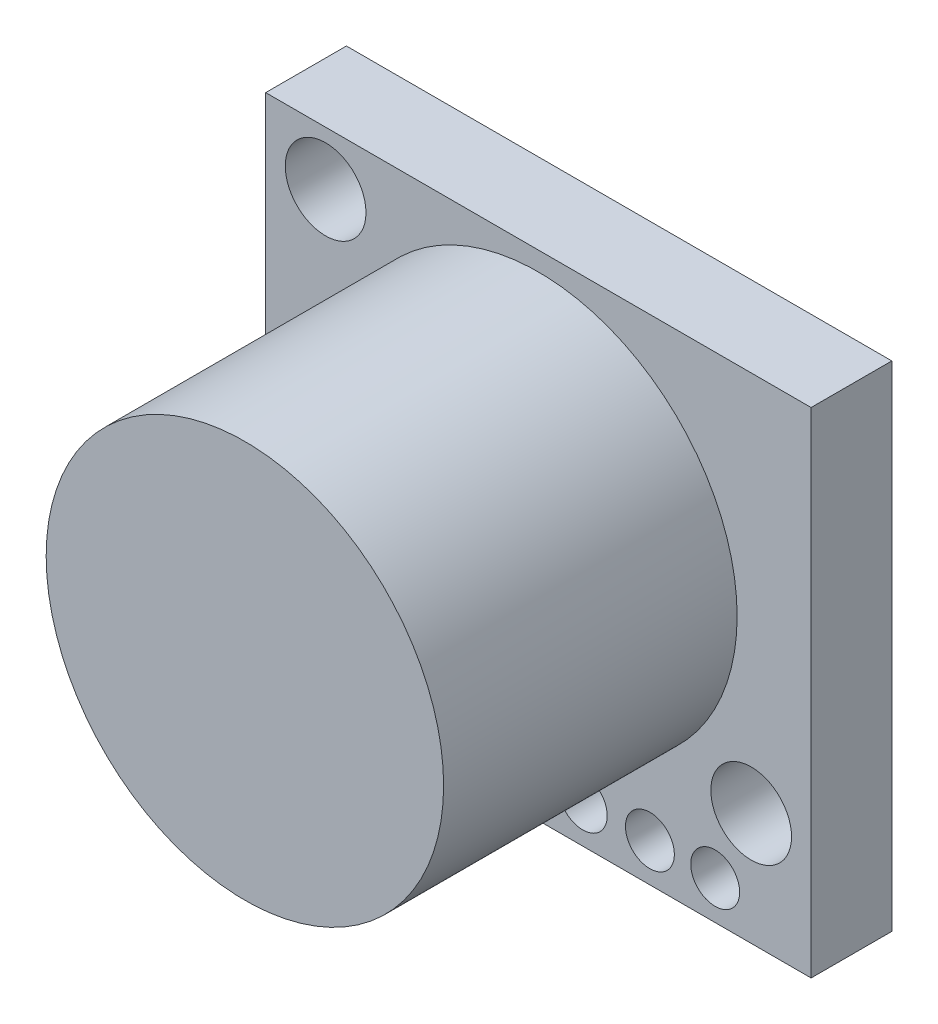
from build123d import *

# Parameters (mm, degrees)
SKETCH1_W           = 22.3
SKETCH1_H           = 20.2
SKETCH1_R           = 1.65
BOSS_EXTRUDE1_DEPTH = 3.3
SKETCH2_R           = 8.125
BOSS_EXTRUDE2_DEPTH = 12
SKETCH2_3_R         = 1
CUT_EXTRUDE1_DEPTH  = 12


with BuildPart() as part:
    # Sketch1 → Boss-Extrude1 (new body)
    with BuildSketch(Plane.XY):
        with Locations((11.15, 10.1)):
            Rectangle(SKETCH1_W, SKETCH1_H)
        with Locations((2.45, 18)):
            Circle(SKETCH1_R, mode=Mode.SUBTRACT)
        with Locations((19.85, 4.6)):
            Circle(SKETCH1_R, mode=Mode.SUBTRACT)
    extrude(amount=BOSS_EXTRUDE1_DEPTH)

    # Sketch2 → Boss-Extrude2 (add)
    with BuildSketch(Plane.XY.offset(3.3)):
        with Locations((11.15, 11.3)):
            Circle(SKETCH2_R)
    extrude(amount=BOSS_EXTRUDE2_DEPTH)

    # Sketch2_3 → Cut-Extrude1 (cut)
    with BuildSketch(Plane.XY.offset(3.3)):
        with Locations((4.353511594, 1.574306631)):
            Circle(SKETCH2_3_R)
        with Locations((7.380273739, 1.574306631)):
            Circle(SKETCH2_3_R)
        with Locations((12.963803906, 1.574306631)):
            Circle(SKETCH2_3_R)
        with Locations((10.237837999, 1.574306631)):
            Circle(SKETCH2_3_R)
        with Locations((15.708569577, 1.574306631)):
            Circle(SKETCH2_3_R)
        with Locations((18.378136189, 1.574306631)):
            Circle(SKETCH2_3_R)
    extrude(amount=-CUT_EXTRUDE1_DEPTH, mode=Mode.SUBTRACT)


solid = part.part
